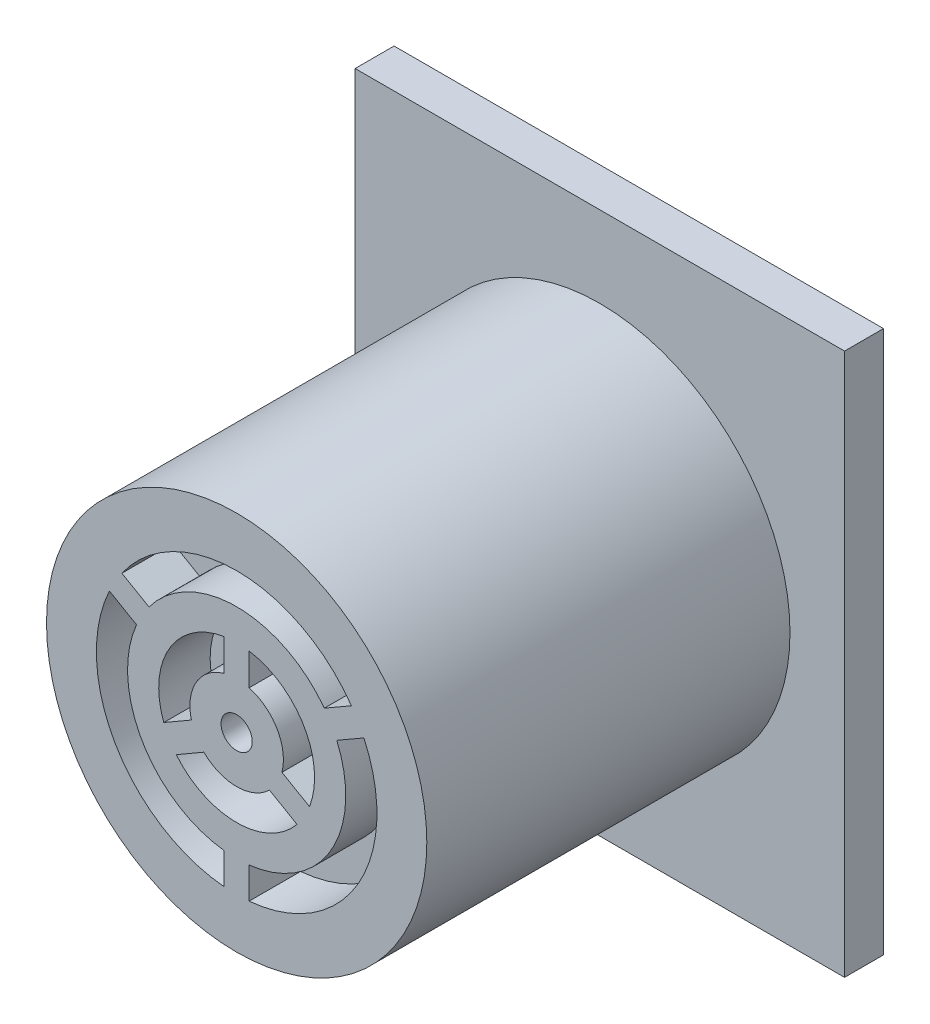
from build123d import *

# Parameters (mm, degrees)
SKETCH1_W      = 19.939
SKETCH1_H      = 22.098
EXTRUDE1_DEPTH = 1.5875
SKETCH2_R      = 7.747
EXTRUDE2_DEPTH = 14.7955
SKETCH3_R      = 0.635
EXTRUDE3_DEPTH = 2.0955


with BuildPart() as part:
    # Sketch1 → Extrude1 (new body)
    with BuildSketch(Plane.XY):
        Rectangle(SKETCH1_W, SKETCH1_H)
    extrude(amount=EXTRUDE1_DEPTH)


with BuildPart() as body_2:
    # Sketch2 → Extrude2 (new body)
    with BuildSketch(Plane.XY.offset(1.5875)):
        Circle(SKETCH2_R)
    extrude(amount=EXTRUDE2_DEPTH)

    # Sketch3 → Extrude3 (cut)
    with BuildSketch(Plane.XY.offset(16.383)):
        with BuildLine():
            Line((3.570260811, 2.647878914), (4.675743477, 3.286129629))
            ThreePointArc((4.675743477, 3.286129629), (0, 5.715), (-4.675743477, 3.286129629))
            Line((-4.675743477, 3.286129629), (-3.570260811, 2.647878914))
            ThreePointArc((-3.570260811, 2.647878914), (0, 4.445), (3.570260811, 2.647878914))
        make_face()
        with BuildLine():
            Line((-4.078260811, 1.767997104), (-5.183743477, 2.406247818))
            ThreePointArc((-5.183743477, 2.406247818), (-4.949335183, -2.8575), (-0.508, -5.692377447))
            Line((-0.508, -5.692377447), (-0.508, -4.415876017))
            ThreePointArc((-0.508, -4.415876017), (-3.84948292, -2.2225), (-4.078260811, 1.767997104))
        make_face()
        with BuildLine():
            Line((-0.508, 1.836017701), (-0.508, 3.134096521))
            ThreePointArc((-0.508, 3.134096521), (-2.749630657, 1.5875), (-2.968207205, -1.127107355))
            Line((-2.968207205, -1.127107355), (-1.844037971, -0.478067946))
            ThreePointArc((-1.844037971, -0.478067946), (-1.649778394, 0.9525), (-0.508, 1.836017701))
        make_face()
        with BuildLine():
            Line((-1.336037971, -1.357949756), (-2.460207205, -2.006989165))
            ThreePointArc((-2.460207205, -2.006989165), (0, -3.175), (2.460207205, -2.006989165))
            Line((2.460207205, -2.006989165), (1.336037971, -1.357949756))
            ThreePointArc((1.336037971, -1.357949756), (0, -1.905), (-1.336037971, -1.357949756))
        make_face()
        Circle(SKETCH3_R)
        with BuildLine():
            Line((1.844037971, -0.478067946), (2.968207205, -1.127107355))
            ThreePointArc((2.968207205, -1.127107355), (2.749630657, 1.5875), (0.508, 3.134096521))
            Line((0.508, 3.134096521), (0.508, 1.836017701))
            ThreePointArc((0.508, 1.836017701), (1.649778394, 0.9525), (1.844037971, -0.478067946))
        make_face()
        with BuildLine():
            ThreePointArc((0.508, -4.415876017), (3.84948292, -2.2225), (4.078260811, 1.767997104))
            Line((4.078260811, 1.767997104), (5.183743477, 2.406247818))
            ThreePointArc((5.183743477, 2.406247818), (4.949335183, -2.8575), (0.508, -5.692377447))
            Line((0.508, -5.692377447), (0.508, -4.415876017))
        make_face()
    extrude(amount=-EXTRUDE3_DEPTH, mode=Mode.SUBTRACT)


solid = Compound([part.part, body_2.part])
